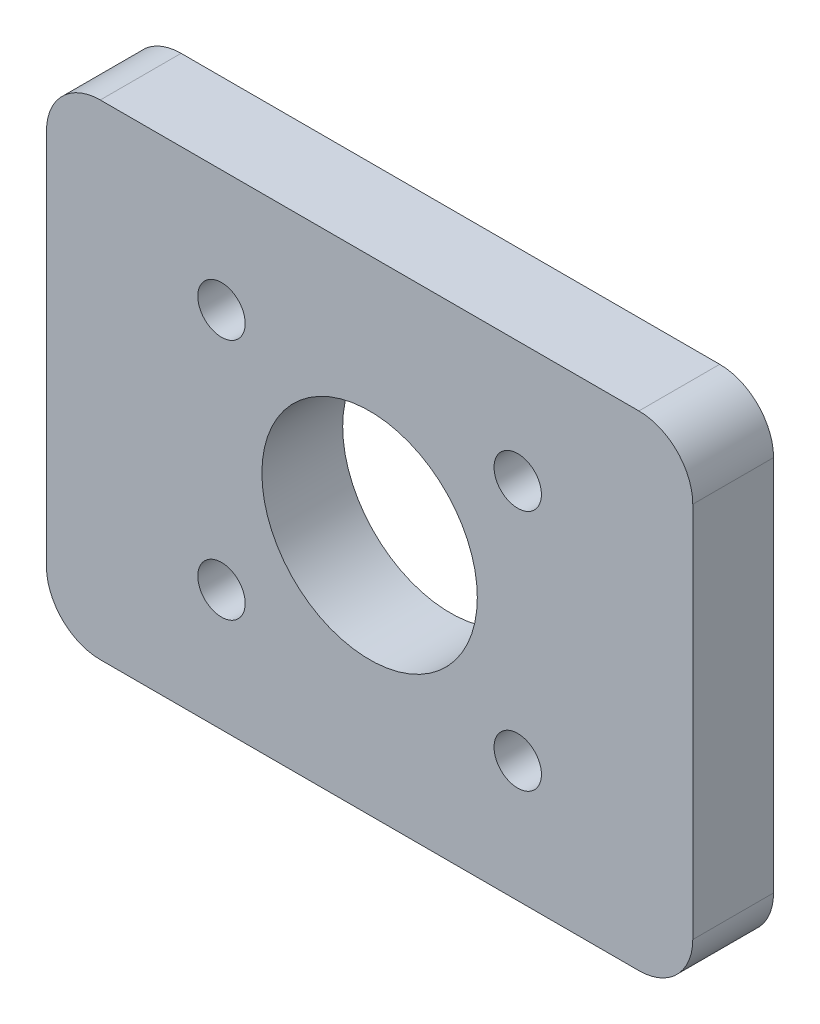
from build123d import *

# Parameters (mm, degrees)
SKETCH1_R           = 4.4
SKETCH1_R_2         = 20
BOSS_EXTRUDE1_DEPTH = 15


with BuildPart() as part:
    # Sketch1 → Boss-Extrude1 (new body)
    with BuildSketch(Plane.XY):
        with BuildLine():
            Line((-50, 45), (50, 45))
            ThreePointArc((50, 45), (57.071067812, 42.071067812), (60, 35))
            Line((60, 35), (60, -35))
            ThreePointArc((60, -35), (57.071067812, -42.071067812), (50, -45))
            Line((50, -45), (-50, -45))
            ThreePointArc((-50, -45), (-57.071067812, -42.071067812), (-60, -35))
            Line((-60, -35), (-60, 35))
            ThreePointArc((-60, 35), (-57.071067812, 42.071067812), (-50, 45))
        make_face()
        with Locations((-27.5, 22.5)):
            Circle(SKETCH1_R, mode=Mode.SUBTRACT)
        with Locations((27.5, 22.5)):
            Circle(SKETCH1_R, mode=Mode.SUBTRACT)
        with Locations((-27.5, -22.5)):
            Circle(SKETCH1_R, mode=Mode.SUBTRACT)
        with Locations((27.5, -22.5)):
            Circle(SKETCH1_R, mode=Mode.SUBTRACT)
        Circle(SKETCH1_R_2, mode=Mode.SUBTRACT)
    extrude(amount=BOSS_EXTRUDE1_DEPTH)


solid = part.part
